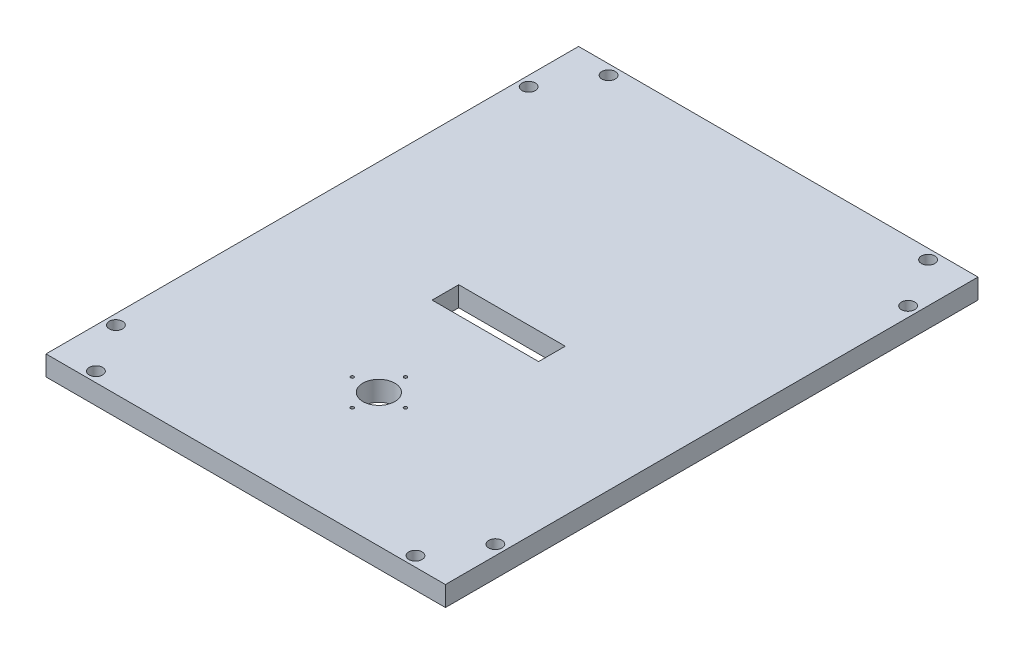
from build123d import *

# Parameters (mm, degrees)
CROQUIS1_R              = 0.6
CROQUIS1_R_2            = 6
SALIENTE_EXTRUIR2_DEPTH = 7.5
CROQUIS4_R              = 2.5
CORTAR_EXTRUIR1_DEPTH   = 7.5


with BuildPart() as part:
    # Croquis1 → Saliente-Extruir2 (new body)
    with BuildSketch(Plane(origin=(0, 0, 0), x_dir=(1, 0, 0), z_dir=(0, 1, 0))):
        Polygon((0, 200), (0, 100), (55, 100), (95, 100), (150, 100), (150, 200), align=None)
        Polygon((55, 100), (0, 100), (0, 0), (150, 0), (150, 100), (95, 100), (95, 90), (75, 90), (55, 90), align=None)
        with Locations((75, 40)):
            Circle(CROQUIS1_R, mode=Mode.SUBTRACT)
        with Locations((65, 50)):
            Circle(CROQUIS1_R, mode=Mode.SUBTRACT)
        with Locations((75, 50)):
            Circle(CROQUIS1_R_2, mode=Mode.SUBTRACT)
        with Locations((75, 60)):
            Circle(CROQUIS1_R, mode=Mode.SUBTRACT)
        with Locations((85, 50)):
            Circle(CROQUIS1_R, mode=Mode.SUBTRACT)
    extrude(amount=SALIENTE_EXTRUIR2_DEPTH)

    # Croquis4 → Cortar-Extruir1 (cut)
    with BuildSketch(Plane.XZ):
        with Locations((135, -3.75)):
            Circle(CROQUIS4_R)
        with Locations((146.25, -22.5)):
            Circle(CROQUIS4_R)
        with Locations((3.75, -22.5)):
            Circle(CROQUIS4_R)
        with Locations((15, -3.75)):
            Circle(CROQUIS4_R)
        with Locations((146.25, -177.5)):
            Circle(CROQUIS4_R)
        with Locations((135, -196.25)):
            Circle(CROQUIS4_R)
        with Locations((3.75, -177.5)):
            Circle(CROQUIS4_R)
        with Locations((15, -196.25)):
            Circle(CROQUIS4_R)
    extrude(amount=-CORTAR_EXTRUIR1_DEPTH, mode=Mode.SUBTRACT)


solid = part.part
